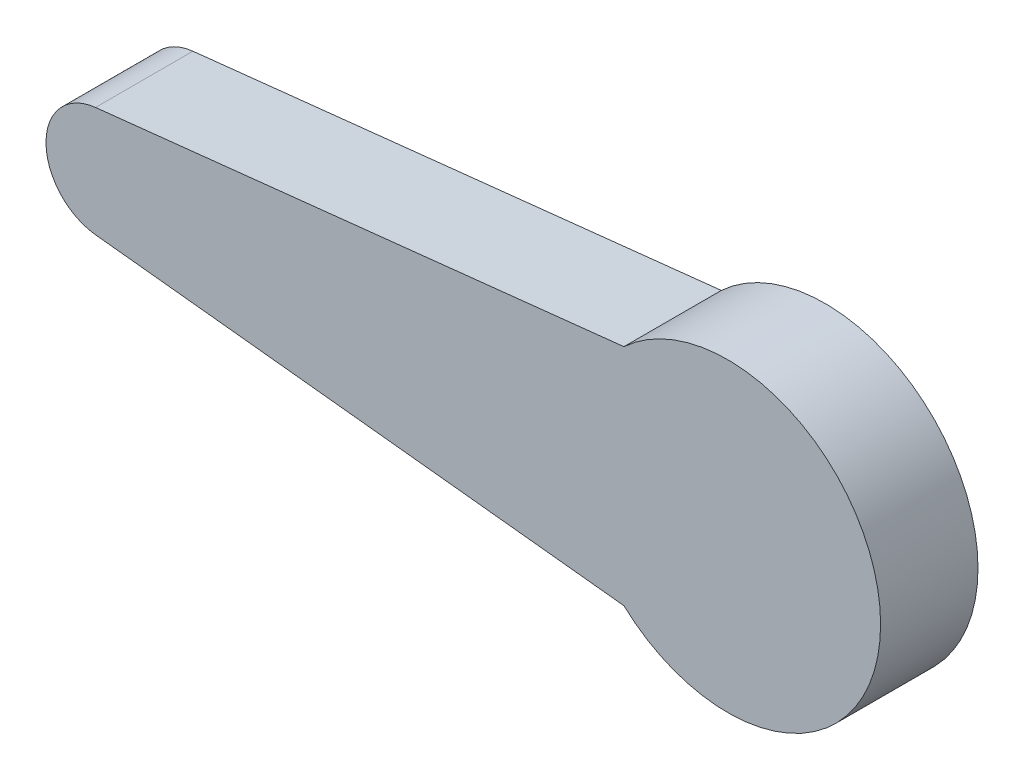
from build123d import *

# Parameters (mm, degrees)
BOSS_EXTRUDE6_DEPTH = 4
CUT_EXTRUDE1_DEPTH  = 2


with BuildPart() as part:
    # Sketch2 → Boss-Extrude6 (new body)
    with BuildSketch(Plane.XY):
        with BuildLine():
            Line((7.936945185, 4.607509822), (-13.764834635, 2.265131203))
            ThreePointArc((-13.764834635, 2.265131203), (-15.798635322, 0), (-13.764834635, -2.265131203))
            Line((-13.764834635, -2.265131203), (7.936945185, -4.607509822))
            ThreePointArc((7.936945185, -4.607509822), (18.479455181, 0), (7.936945185, 4.607509822))
        make_face()
    extrude(amount=BOSS_EXTRUDE6_DEPTH)

    # Sketch1 → Cut-Extrude1 (cut)
    with BuildSketch(Plane.XY):
        with BuildLine():
            Line((-2.308259951, 2.498066053), (9.375044145, 3.190055955))
            add(Edge.make_bspline(
                [(9.375044145, 3.190055955), (9.743762717, 3.535051607), (10.542113364, 3.885379294), (11.739855888, 4.053778423), (12.781606273, 3.904003548), (13.647647588, 3.58835165), (14.172524986, 3.123610305), (14.749448402, 2.727996587), (15.239395752, 2.01553181), (15.653528757, 1.050879588), (15.788992815, -0.000691818), (15.651665108, -1.048112313), (15.246850359, -2.025217286), (14.603250264, -2.863967716), (13.764299096, -3.507779486), (12.787785525, -3.91194775), (11.73820132, -4.051651269), (10.542857019, -3.886335356), (9.743600409, -3.534842939), (9.375044145, -3.190055955)],
                knots=[0, 0, 0, 0, 0.085136877, 0.144403023, 0.203669169, 0.262935434, 0.297502717, 0.322201499, 0.3814676, 0.440733879, 0.5, 0.559266121, 0.6185324, 0.677798501, 0.737064566, 0.796330831, 0.855596977, 0.914863123, 1, 1, 1, 1], degree=3))
            Line((9.375044145, -3.190055955), (-2.308259951, -2.498066053))
            add(Edge.make_bspline(
                [(-2.308259951, -2.498066053), (-2.730270965, -2.498681523), (-3.365255191, -2.317767142), (-4.051947117, -1.791219452), (-4.45450445, -1.266528616), (-4.707556493, -0.655614107), (-4.793872131, 0), (-4.707556493, 0.655614107), (-4.45450445, 1.266528616), (-4.051947117, 1.791219452), (-3.365255191, 2.317767142), (-2.730270965, 2.498681523), (-2.308259951, 2.498066053)],
                knots=[0, 0, 0, 0, 0.162547316, 0.2469105, 0.331273485, 0.415637006, 0.5, 0.584362994, 0.668726515, 0.7530895, 0.837452684, 1, 1, 1, 1], degree=3))
        make_face()
    extrude(amount=CUT_EXTRUDE1_DEPTH, mode=Mode.SUBTRACT)


solid = part.part
